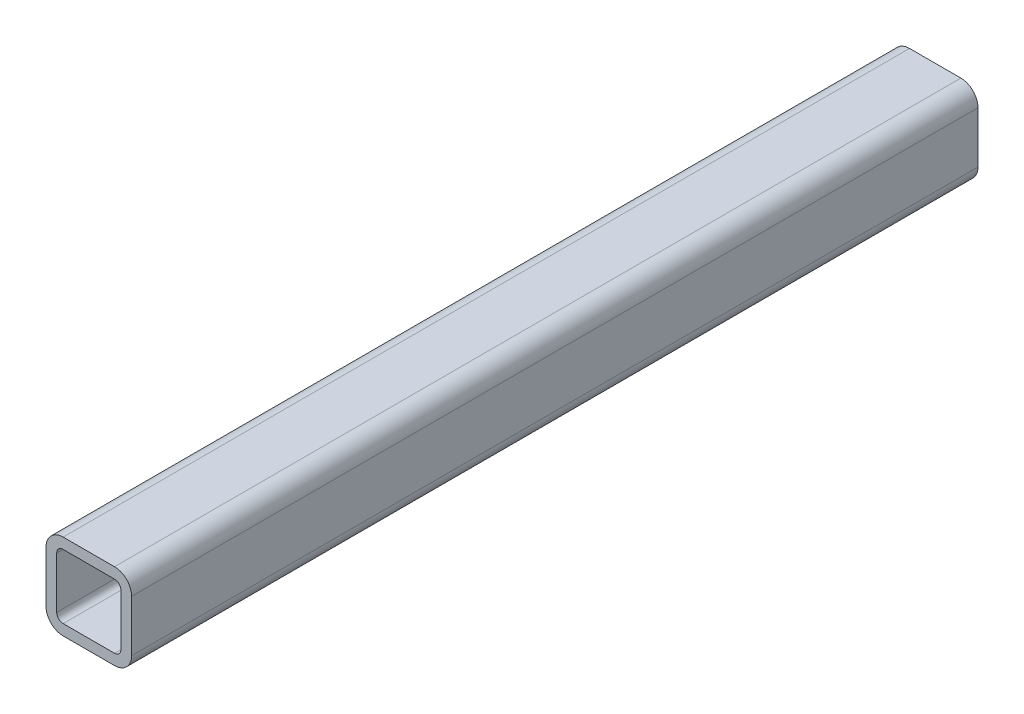
from build123d import *

# Parameters (mm, degrees)
SQUARE_TUBING_1_X_1_X_0_125_1_DEPTH = 251.1044


with BuildPart() as part:
    # Sketch11 → Square tubing 1 X 1 X 0.125(1) (new body)
    with BuildSketch(Plane.YX):
        with BuildLine():
            Line((-7.62, -12.7), (7.62, -12.7))
            ThreePointArc((7.62, -12.7), (11.212102448, -11.212102448), (12.7, -7.62))
            Line((12.7, -7.62), (12.7, 7.62))
            ThreePointArc((12.7, 7.62), (11.212102448, 11.212102448), (7.62, 12.7))
            Line((7.62, 12.7), (-7.62, 12.7))
            ThreePointArc((-7.62, 12.7), (-11.212102448, 11.212102448), (-12.7, 7.62))
            Line((-12.7, 7.62), (-12.7, -7.62))
            ThreePointArc((-12.7, -7.62), (-11.212102448, -11.212102448), (-7.62, -12.7))
        make_face()
        with BuildLine():
            Line((-7.62, -9.525), (7.62, -9.525))
            ThreePointArc((7.62, -9.525), (8.967038418, -8.967038418), (9.525, -7.62))
            Line((9.525, -7.62), (9.525, 7.62))
            ThreePointArc((9.525, 7.62), (8.967038418, 8.967038418), (7.62, 9.525))
            Line((7.62, 9.525), (-7.62, 9.525))
            ThreePointArc((-7.62, 9.525), (-8.967038418, 8.967038418), (-9.525, 7.62))
            Line((-9.525, 7.62), (-9.525, -7.62))
            ThreePointArc((-9.525, -7.62), (-8.967038418, -8.967038418), (-7.62, -9.525))
        make_face(mode=Mode.SUBTRACT)
    extrude(amount=SQUARE_TUBING_1_X_1_X_0_125_1_DEPTH)


solid = part.part
